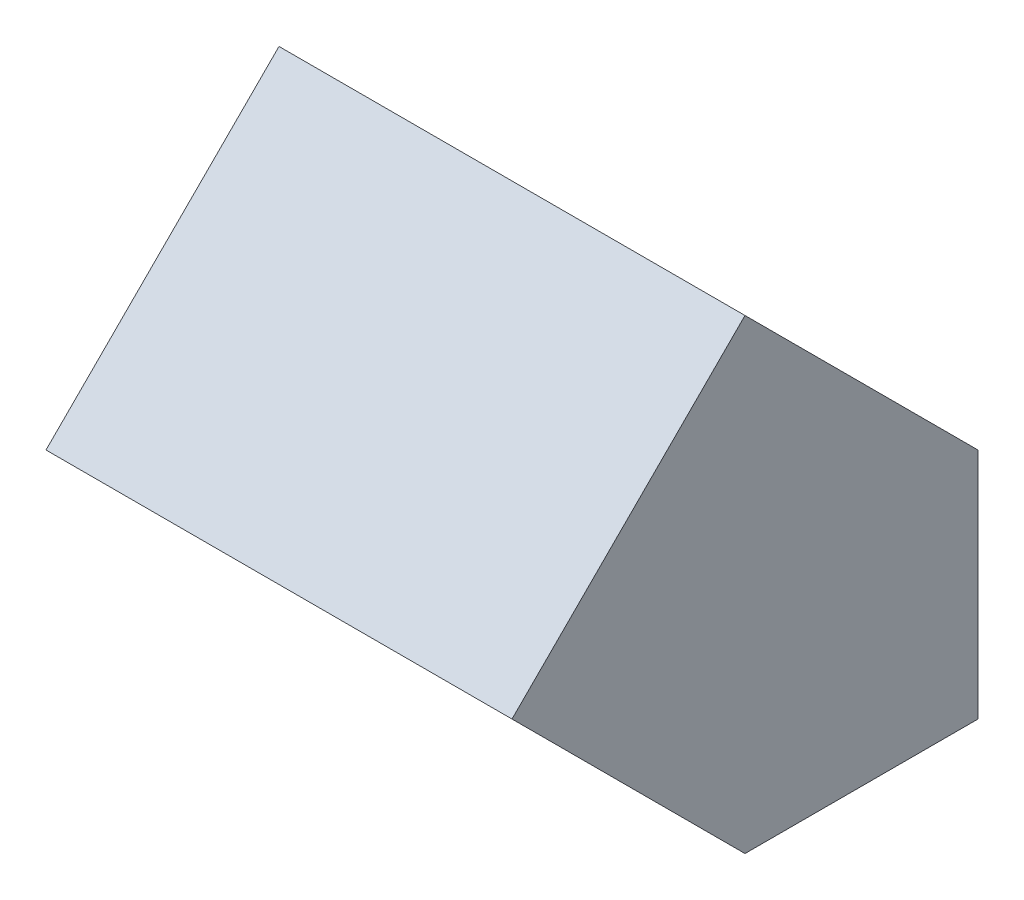
from build123d import *

# Parameters (mm, degrees)
SKETCH1_W           = 40
SKETCH1_H           = 40
BOSS_EXTRUDE1_DEPTH = 40
CUT_EXTRUDE1_DEPTH  = 40
CUT_EXTRUDE2_DEPTH  = 40


with BuildPart() as part:
    # Sketch1 → Boss-Extrude1 (new body)
    with BuildSketch(Plane.XY):
        with Locations((20, 20)):
            Rectangle(SKETCH1_W, SKETCH1_H)
    extrude(amount=BOSS_EXTRUDE1_DEPTH)

    # Sketch2 → Cut-Extrude1 (cut)
    with BuildSketch(Plane.ZY):
        Polygon((20, 40), (40, 20), (40, 40), align=None)
        Polygon((40, 20), (20, 0), (40, 0), align=None)
    extrude(amount=-CUT_EXTRUDE1_DEPTH, mode=Mode.SUBTRACT)

    # Sketch3 → Cut-Extrude2 (cut)
    with BuildSketch(Plane(origin=(0, 0, 0), x_dir=(0, 0, -1), z_dir=(1, 0, 0))):
        Polygon((-20, 40), (0, 20), (0, 40), align=None)
    extrude(amount=CUT_EXTRUDE2_DEPTH, mode=Mode.SUBTRACT)


solid = part.part
